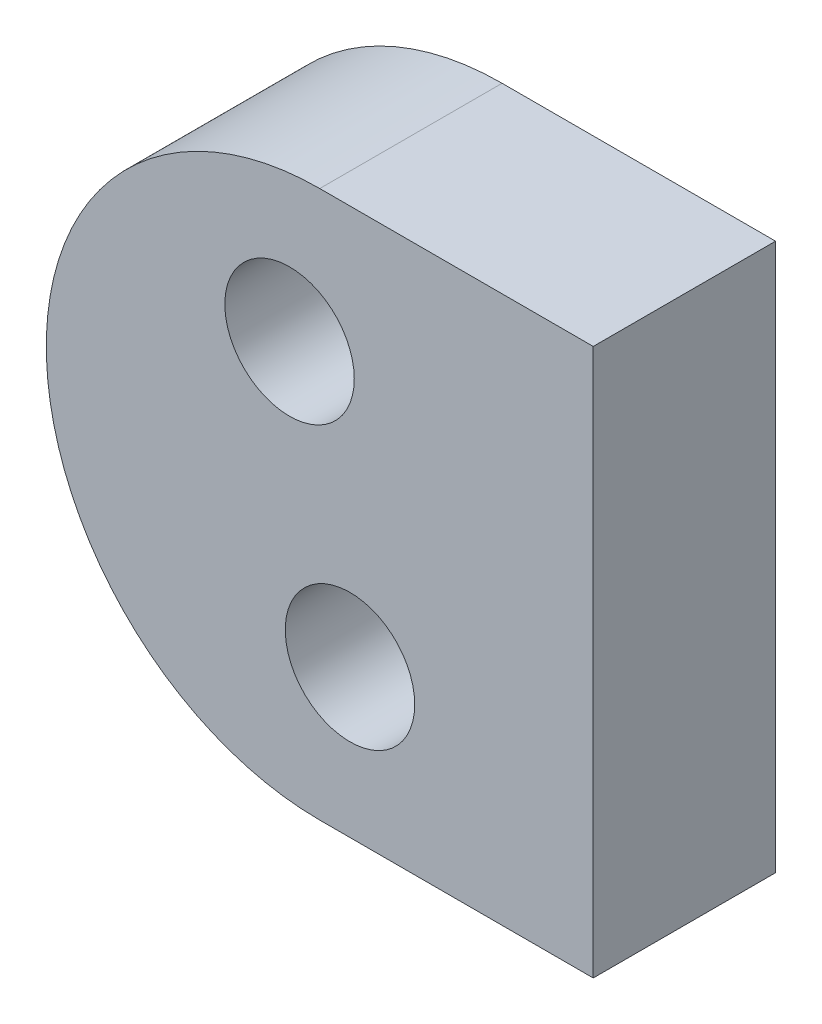
from build123d import *

# Parameters (mm, degrees)
SKETCH1_R           = 0.8875
BOSS_EXTRUDE1_DEPTH = 2.5


with BuildPart() as part:
    # Sketch1 → Boss-Extrude1 (new body)
    with BuildSketch(Plane.XY):
        with BuildLine():
            Line((0.414365521, 2.024043391), (4.164365521, 2.024043391))
            Line((4.164365521, 2.024043391), (4.164365521, -5.475956609))
            Line((4.164365521, -5.475956609), (0.414365521, -5.475956609))
            ThreePointArc((0.414365521, -5.475956609), (-3.335634479, -1.725956609), (0.414365521, 2.024043391))
        make_face()
        Circle(SKETCH1_R, mode=Mode.SUBTRACT)
        with Locations((0.828731042, -3.451913217)):
            Circle(SKETCH1_R, mode=Mode.SUBTRACT)
    extrude(amount=BOSS_EXTRUDE1_DEPTH)


solid = part.part
